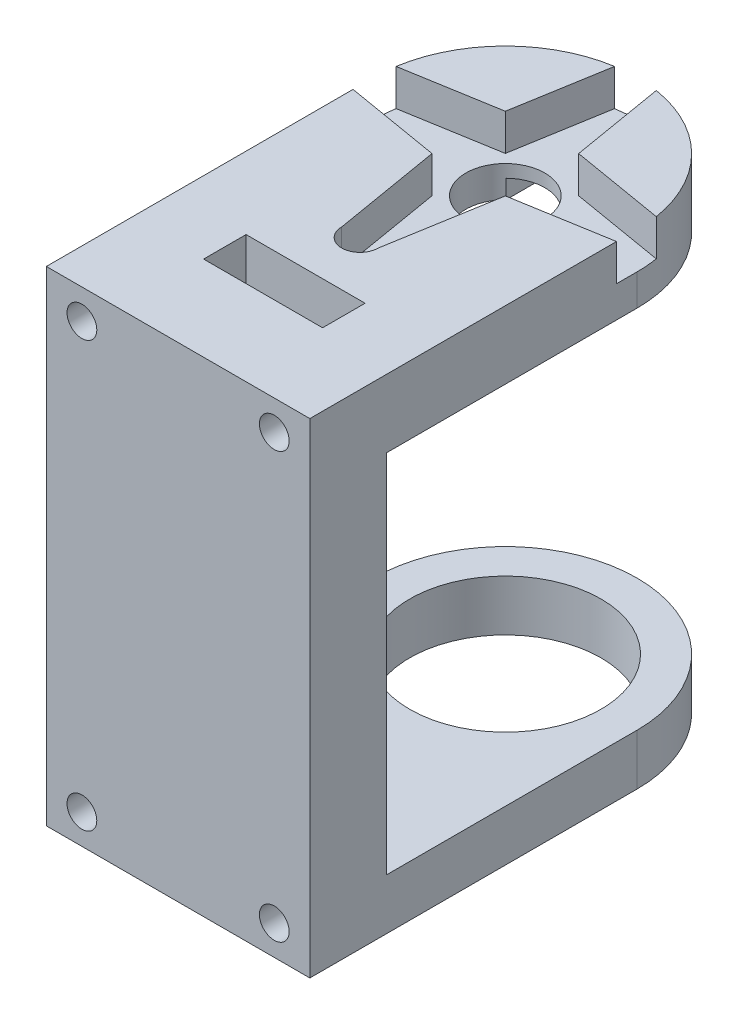
from build123d import *

# Parameters (mm, degrees)
BOSS_EXTRUDE1_DEPTH = 9
SKETCH4_W           = 31
SKETCH4_H           = 8
SKETCH4_H_2         = 6
BOSS_EXTRUDE4_DEPTH = 45
CUT_EXTRUDE1_DEPTH  = 58
SKETCH6_3_R         = 11.25
CUT_EXTRUDE2_DEPTH  = 6
CUT_EXTRUDE3_DEPTH  = 4.3
CUT_EXTRUDE4_DEPTH  = 2.2
SKETCH9_3_R         = 4.65
CUT_EXTRUDE5_DEPTH  = 8
SKETCH13_W          = 14
SKETCH13_H          = 5
CUT_EXTRUDE8_DEPTH  = 9
SKETCH14_R          = 1.75
CUT_EXTRUDE9_DEPTH  = 3


with BuildPart() as part:
    # Sketch1 → Boss-Extrude1 (new body)
    with BuildSketch(Plane.XY):
        Polygon((15.5, -28.5), (-15.5, -28.5), (-15.5, -10.3), (-15.5, 10.3), (-15.5, 28.5), (15.5, 28.5), align=None)
    extrude(amount=BOSS_EXTRUDE1_DEPTH)

    # Sketch4 → Boss-Extrude4 (add)
    with BuildSketch(Plane(origin=(0, 0, 0), x_dir=(-1, 0, 0), z_dir=(0, 0, -1))):
        with Locations((0, 24.5)):
            Rectangle(SKETCH4_W, SKETCH4_H)
        with Locations((0, -25.5)):
            Rectangle(SKETCH4_W, SKETCH4_H_2)
    extrude(amount=BOSS_EXTRUDE4_DEPTH)

    # Sketch6 → Cut-Extrude1 (cut, through all)
    with BuildSketch(Plane.XZ.offset(28.5)):
        with BuildLine():
            ThreePointArc((15.5, -29.5), (10.960155101, -40.460155116), (-2.1e-08, -45))
            Line((-2.1e-08, -45), (15.5, -45))
            Line((15.5, -45), (15.5, -29.5))
        make_face()
        with BuildLine():
            ThreePointArc((-2.1e-08, -45), (-10.960155116, -40.460155101), (-15.5, -29.5))
            Line((-15.5, -29.5), (-15.5, -45))
            Line((-15.5, -45), (-2.1e-08, -45))
        make_face()
    extrude(amount=-CUT_EXTRUDE1_DEPTH, mode=Mode.SUBTRACT)

    # Sketch6_3 → Cut-Extrude2 (cut)
    with BuildSketch(Plane.XZ.offset(28.5)):
        with Locations((0, -29.5)):
            Circle(SKETCH6_3_R)
    extrude(amount=-CUT_EXTRUDE2_DEPTH, mode=Mode.SUBTRACT)

    # Sketch7 → Cut-Extrude3 (cut)
    with BuildSketch(Plane(origin=(0, 28.5, 0), x_dir=(1, 0, 0), z_dir=(0, 1, 0))):
        with BuildLine():
            Line((-17.1, 31.65), (-4.313351365, 33.813351365))
            Line((-4.313351365, 33.813351365), (-2.15, 46.6))
            ThreePointArc((-2.15, 46.6), (0, 48.75), (2.15, 46.6))
            Line((2.15, 46.6), (4.313351365, 33.813351365))
            Line((4.313351365, 33.813351365), (17.1, 31.65))
            ThreePointArc((17.1, 31.65), (19.25, 29.5), (17.1, 27.35))
            Line((17.1, 27.35), (4.313351365, 25.186648635))
            Line((4.313351365, 25.186648635), (2.15, 12.4))
            ThreePointArc((2.15, 12.4), (0, 10.25), (-2.15, 12.4))
            Line((-2.15, 12.4), (-4.313351365, 25.186648635))
            Line((-4.313351365, 25.186648635), (-17.1, 27.35))
            ThreePointArc((-17.1, 27.35), (-19.25, 29.5), (-17.1, 31.65))
        make_face()
    extrude(amount=-CUT_EXTRUDE3_DEPTH, mode=Mode.SUBTRACT)

    # Sketch9 → Cut-Extrude4 (cut)
    with BuildSketch(Plane.XZ.offset(-20.5)):
        with BuildLine():
            ThreePointArc((3.25, -32.82565783), (0, -34.15), (-3.25, -32.82565783))
            Line((-3.25, -32.82565783), (-3.25, -44.655444566))
            ThreePointArc((-3.25, -44.655444566), (0, -45), (3.25, -44.655444566))
            Line((3.25, -44.655444566), (3.25, -32.82565783))
        make_face()
    extrude(amount=-CUT_EXTRUDE4_DEPTH, mode=Mode.SUBTRACT)

    # Sketch9_3 → Cut-Extrude5 (cut)
    with BuildSketch(Plane.XZ.offset(-20.5)):
        with Locations((0, -29.5)):
            Circle(SKETCH9_3_R)
    extrude(amount=-CUT_EXTRUDE5_DEPTH, mode=Mode.SUBTRACT)

    # Sketch13 → Cut-Extrude8 (cut)
    with BuildSketch(Plane(origin=(0, 28.5, 0), x_dir=(1, 0, 0), z_dir=(0, 1, 0))):
        with Locations((0, 3.5)):
            Rectangle(SKETCH13_W, SKETCH13_H)
    extrude(amount=-CUT_EXTRUDE8_DEPTH, mode=Mode.SUBTRACT)

    # Sketch14 → Cut-Extrude9 (cut)
    with BuildSketch(Plane.XY.offset(9)):
        with Locations((11.31642939, 25)):
            Circle(SKETCH14_R)
        with Locations((-11.31642939, 25)):
            Circle(SKETCH14_R)
        with Locations((11.31642939, -25)):
            Circle(SKETCH14_R)
        with Locations((-11.31642939, -25)):
            Circle(SKETCH14_R)
    extrude(amount=-CUT_EXTRUDE9_DEPTH, mode=Mode.SUBTRACT)


solid = part.part
